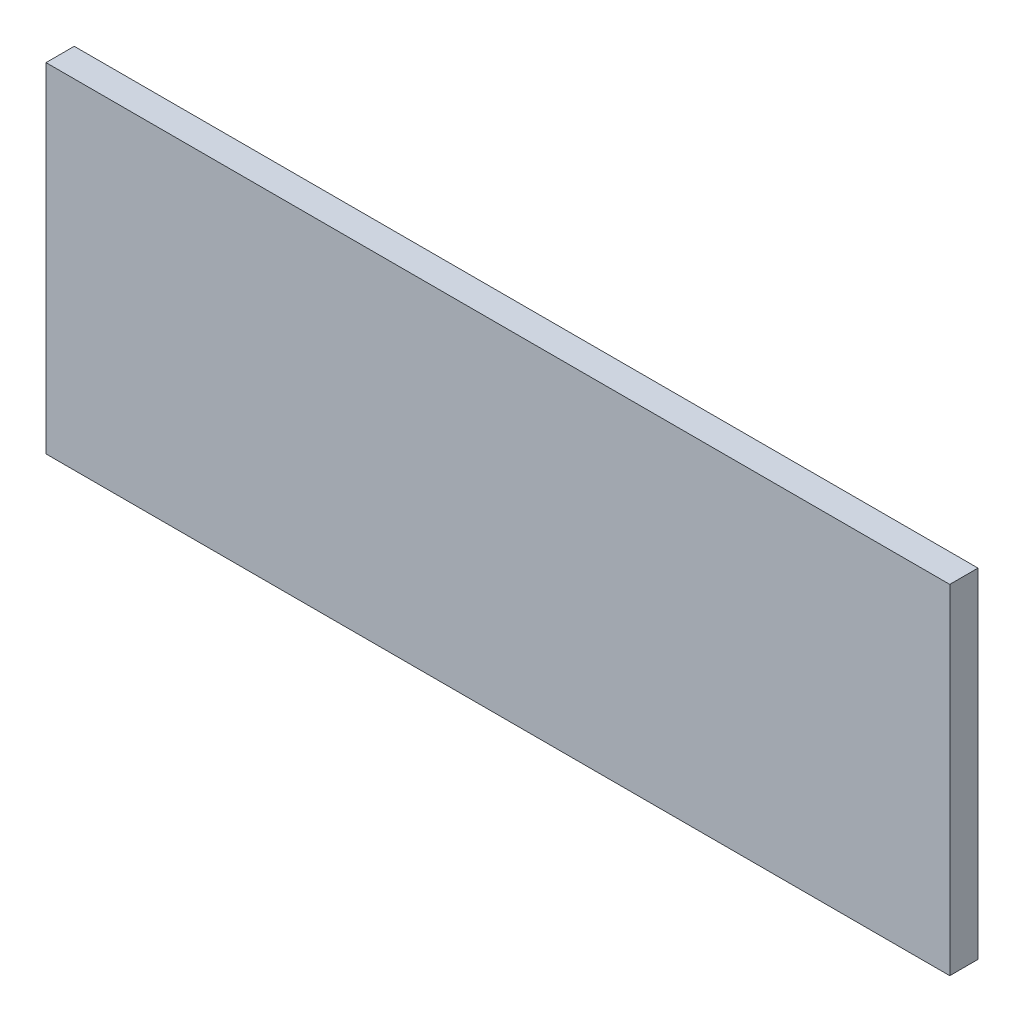
from build123d import *

# Parameters (mm, degrees)
SKETCH1_W           = 609.6
SKETCH1_H           = 228.6
BOSS_EXTRUDE1_DEPTH = 19.05


with BuildPart() as part:
    # Sketch1 → Boss-Extrude1 (new body)
    with BuildSketch(Plane.XY):
        with Locations((304.8, -114.3)):
            Rectangle(SKETCH1_W, SKETCH1_H)
    extrude(amount=BOSS_EXTRUDE1_DEPTH)


solid = part.part
